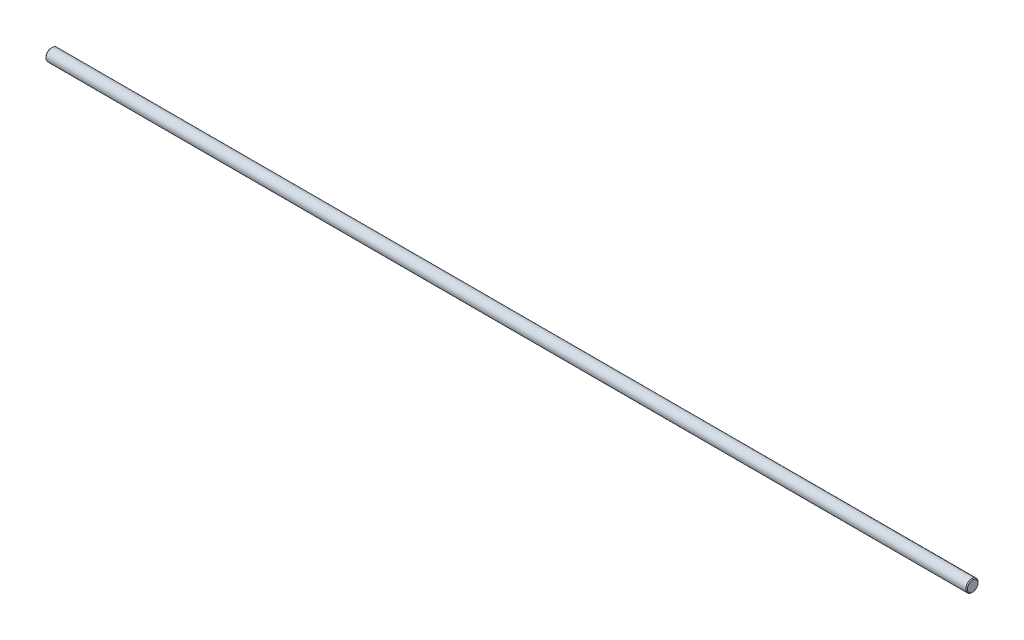
from build123d import *

# Parameters (mm, degrees)
ESQUISSE1_R        = 1.5
BOSS_EXTRU_1_DEPTH = 226
CHANFREIN1_SIZE    = 0.2


with BuildPart() as part:
    # Esquisse1 → Boss.-Extru.1 (new body)
    with BuildSketch(Plane(origin=(0, 0, 0), x_dir=(0, 0, -1), z_dir=(1, 0, 0))):
        Circle(ESQUISSE1_R)
    extrude(amount=BOSS_EXTRU_1_DEPTH)

    # Chanfrein1
    chanfrein1_edges = [part.edges().sort_by_distance(p)[0] for p in [
        (0, 0, 1.5),
        (226, 0, 1.5),
    ]]
    chamfer(chanfrein1_edges, length=CHANFREIN1_SIZE)


solid = part.part
